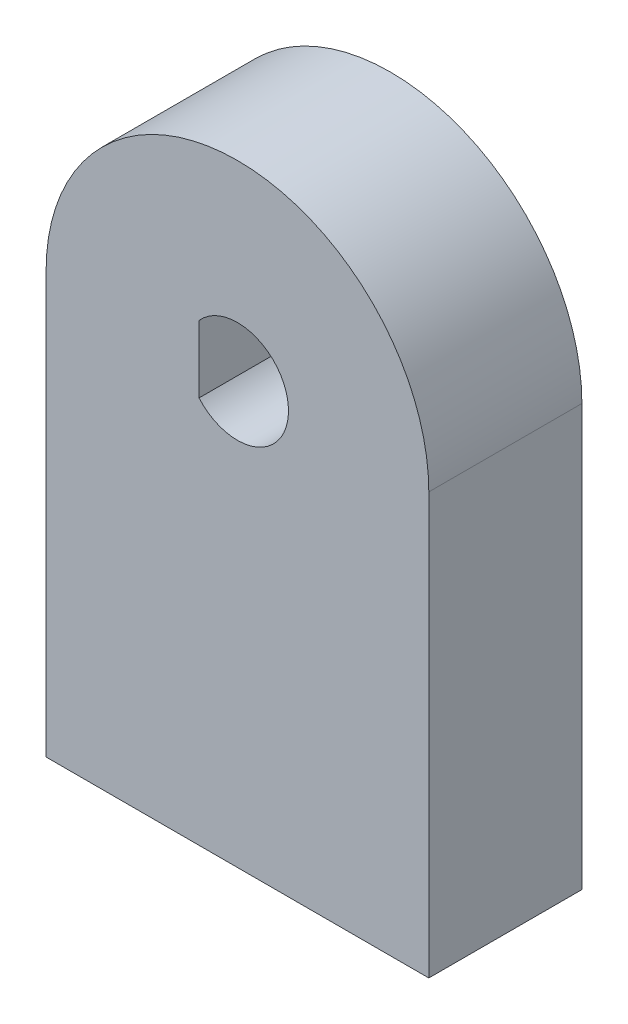
from build123d import *

# Parameters (mm, degrees)
SKETCH2_R           = 15
SKETCH2_R_2         = 11
BOSS_EXTRUDE1_DEPTH = 4
SKETCH3_R           = 15
SKETCH3_R_2         = 4
BOSS_EXTRUDE2_DEPTH = 8
BOSS_EXTRUDE5_DEPTH = 12
BOSS_EXTRUDE7_DEPTH = 8
SKETCH9_R           = 2.875
CUT_EXTRUDE1_DEPTH  = 14


with BuildPart() as part:
    # Sketch2 → Boss-Extrude1 (new body)
    with BuildSketch(Plane.XY):
        Circle(SKETCH2_R)
        Circle(SKETCH2_R_2, mode=Mode.SUBTRACT)
    extrude(amount=BOSS_EXTRUDE1_DEPTH)

    # Sketch3 → Boss-Extrude2 (add)
    with BuildSketch(Plane.XY.offset(4)):
        Circle(SKETCH3_R)
        Circle(SKETCH3_R_2, mode=Mode.SUBTRACT)
    extrude(amount=BOSS_EXTRUDE2_DEPTH)

    # Sketch6 → Boss-Extrude5 (add)
    with BuildSketch(Plane.XY.offset(12)):
        with BuildLine():
            Line((-15, 0), (-15, -33))
            Line((-15, -33), (15, -33))
            Line((15, -33), (15, 0))
            ThreePointArc((15, 0), (0, -15), (-15, 0))
        make_face()
    extrude(amount=-BOSS_EXTRUDE5_DEPTH)

    # Sketch8 → Boss-Extrude7 (add)
    with BuildSketch(Plane.XY.offset(12)):
        with BuildLine():
            Line((-3.013818176, 2.63), (-3.013818176, -2.63))
            ThreePointArc((-3.013818176, -2.63), (-4, 0), (-3.013818176, 2.63))
        make_face()
    extrude(amount=-BOSS_EXTRUDE7_DEPTH)

    # Sketch9 → Cut-Extrude1 (cut)
    with BuildSketch(Plane.XZ.offset(33)):
        with Locations((-7, 6)):
            Circle(SKETCH9_R)
        with Locations((7, 6)):
            Circle(SKETCH9_R)
    extrude(amount=-CUT_EXTRUDE1_DEPTH, mode=Mode.SUBTRACT)


solid = part.part
